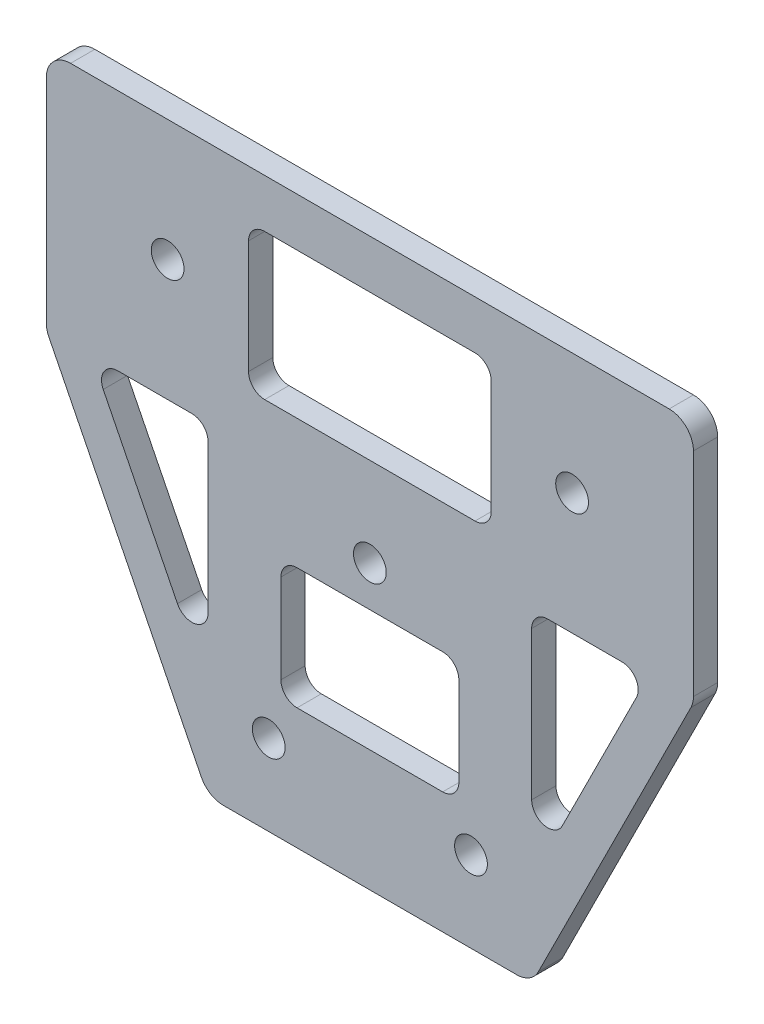
from build123d import *

# Parameters (mm, degrees)
EXTRUDE_1_DEPTH     = 3
SKETCH_2_R          = 2.025
CUT_EXTRUDE_1_DEPTH = 3
SKETCH_3_W          = 30
SKETCH_3_H          = 18
SKETCH_3_W_2        = 22
SKETCH_3_H_2        = 15
CUT_EXTRUDE_2_DEPTH = 3
FILLET_1_R          = 2
FILLET_2_R          = 3


with BuildPart() as part:
    # 草图1 → 凸台-拉伸1 (new body)
    with BuildSketch(Plane.XY):
        Polygon((-40, 0), (40, 0), (40, -30), (20, -70), (-20, -70), (-40, -30), align=None)
    extrude(amount=EXTRUDE_1_DEPTH)

    # 草图2 → 切除-拉伸1 (cut)
    with BuildSketch(Plane.XY.offset(3)):
        with Locations((-25, -15)):
            Circle(SKETCH_2_R)
        with Locations((25, -15)):
            Circle(SKETCH_2_R)
        with Locations((0, -35)):
            Circle(SKETCH_2_R)
        with Locations((12.5, -60)):
            Circle(SKETCH_2_R)
        with Locations((-12.5, -60)):
            Circle(SKETCH_2_R)
    extrude(amount=-CUT_EXTRUDE_1_DEPTH, mode=Mode.SUBTRACT)

    # 草图3 → 切除-拉伸2 (cut)
    with BuildSketch(Plane.XY.offset(3)):
        Polygon((-34.409830056, -30), (-20, -30), (-20, -58.819660113), align=None)
        with Locations((0, -15)):
            Rectangle(SKETCH_3_W, SKETCH_3_H)
        with Locations((0, -47.5)):
            Rectangle(SKETCH_3_W_2, SKETCH_3_H_2)
        Polygon((20, -30), (20, -58.819660113), (34.409830056, -30), align=None)
    extrude(amount=-CUT_EXTRUDE_2_DEPTH, mode=Mode.SUBTRACT)

    # 圆角1
    fillet_1_edges = [part.edges().sort_by_distance(p)[0] for p in [
        (15, -24, 1.5),
        (-15, -24, 1.5),
        (-15, -6, 1.5),
        (15, -6, 1.5),
        (-20, -58.819660113, 1.5),
        (-34.409830056, -30, 1.5),
        (-20, -30, 1.5),
        (11, -55, 1.5),
        (-11, -55, 1.5),
        (-11, -40, 1.5),
        (11, -40, 1.5),
        (34.409830056, -30, 1.5),
        (20, -58.819660113, 1.5),
        (20, -30, 1.5),
    ]]
    fillet(fillet_1_edges, radius=FILLET_1_R)

    # 圆角2
    fillet_2_edges = [part.edges().sort_by_distance(p)[0] for p in [
        (-40, 0, 1.5),
        (40, 0, 1.5),
        (40, -30, 1.5),
        (20, -70, 1.5),
        (-20, -70, 1.5),
        (-40, -30, 1.5),
    ]]
    fillet(fillet_2_edges, radius=FILLET_2_R)


solid = part.part
